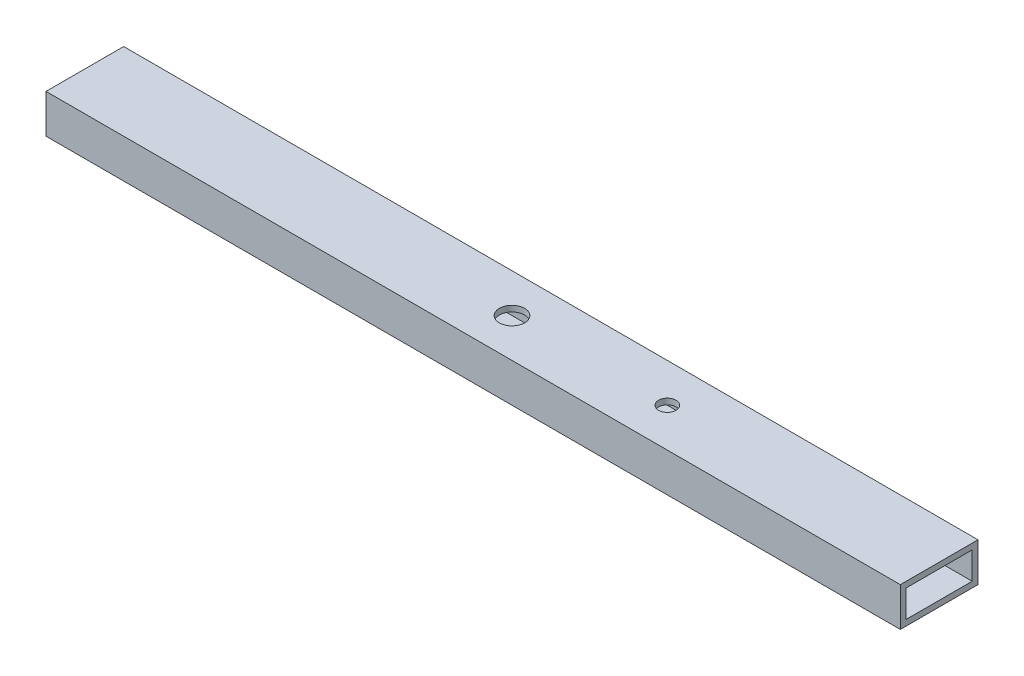
from build123d import *

# Parameters (mm, degrees)
SKETCH1_W           = 20
SKETCH1_H           = 10
SKETCH1_W_2         = 17
SKETCH1_H_2         = 7
BOSS_EXTRUDE1_DEPTH = 220
SKETCH2_R           = 3.25
SKETCH2_R_2         = 2.25
CUT_EXTRUDE1_DEPTH  = 11


with BuildPart() as part:
    # Sketch1 → Boss-Extrude1 (new body)
    with BuildSketch(Plane(origin=(0, 0, 0), x_dir=(0, 0, -1), z_dir=(1, 0, 0))):
        Rectangle(SKETCH1_W, SKETCH1_H)
        Rectangle(SKETCH1_W_2, SKETCH1_H_2, mode=Mode.SUBTRACT)
    extrude(amount=BOSS_EXTRUDE1_DEPTH)

    # Sketch2 → Cut-Extrude1 (cut, through all)
    with BuildSketch(Plane(origin=(0, 5, 0), x_dir=(1, 0, 0), z_dir=(0, 1, 0))):
        with Locations((110, 0)):
            Circle(SKETCH2_R)
        with Locations((150, 0)):
            Circle(SKETCH2_R_2)
    extrude(amount=-CUT_EXTRUDE1_DEPTH, mode=Mode.SUBTRACT)


solid = part.part
